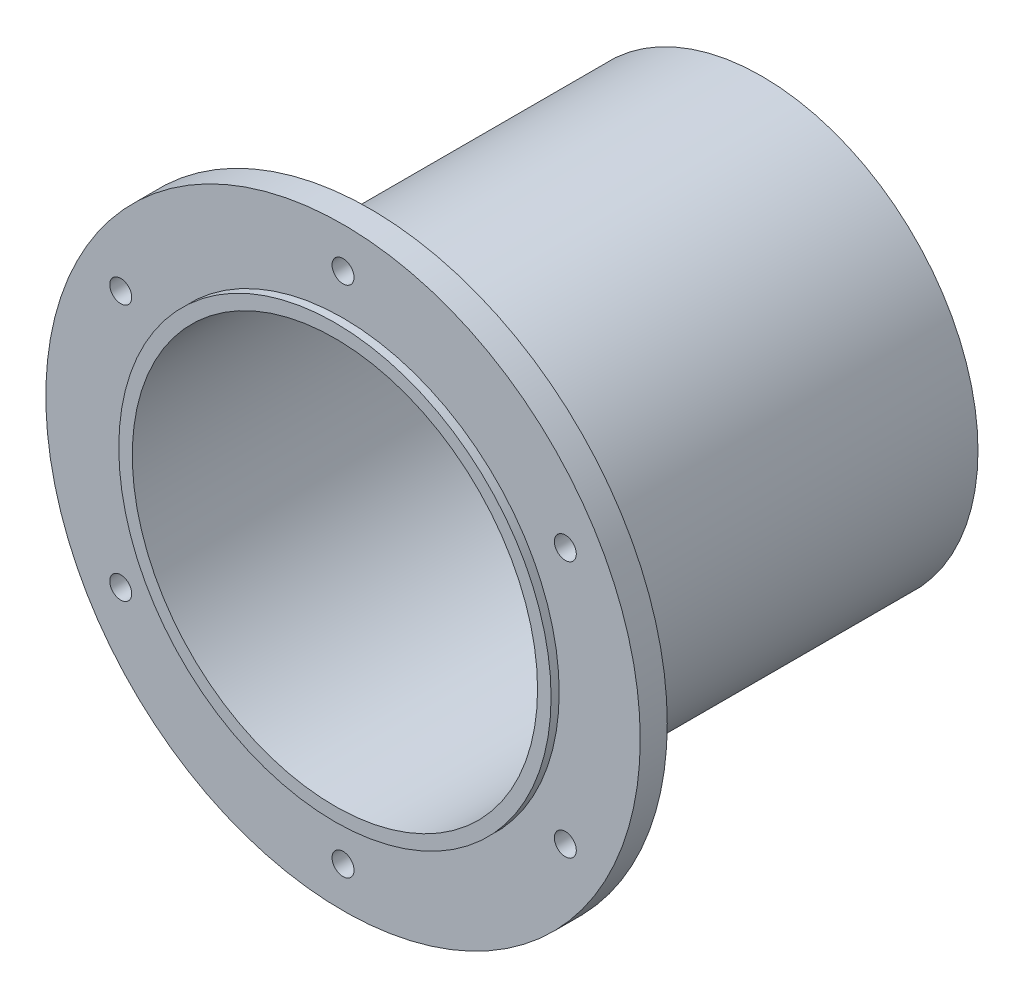
from build123d import *

# Parameters (mm, degrees)
SKETCH1_R           = 69.85
SKETCH1_R_2         = 50.8
SKETCH1_R_3         = 2.57937
EXTRUDE1_DEPTH      = 6.35
SKETCH2_R           = 50.8
SKETCH2_R_2         = 47.625
EXTRUDE2_DEPTH      = 8.255
EXTRUDE2_DEPTH_BACK = 92.075


with BuildPart() as part:
    # Sketch1 → Extrude1 (new body)
    with BuildSketch(Plane.XY):
        Circle(SKETCH1_R)
        Circle(SKETCH1_R_2, mode=Mode.SUBTRACT)
        with Locations((0, 60.325)):
            Circle(SKETCH1_R_3, mode=Mode.SUBTRACT)
        with Locations((-52.242982483, 30.1625)):
            Circle(SKETCH1_R_3, mode=Mode.SUBTRACT)
        with Locations((-52.242982483, -30.1625)):
            Circle(SKETCH1_R_3, mode=Mode.SUBTRACT)
        with Locations((0, -60.325)):
            Circle(SKETCH1_R_3, mode=Mode.SUBTRACT)
        with Locations((52.242982483, -30.1625)):
            Circle(SKETCH1_R_3, mode=Mode.SUBTRACT)
        with Locations((52.242982483, 30.1625)):
            Circle(SKETCH1_R_3, mode=Mode.SUBTRACT)
    extrude(amount=EXTRUDE1_DEPTH)


with BuildPart() as body_2:
    # Sketch2 → Extrude2 (new body, two sides)
    with BuildSketch(Plane.XY) as extrude2_sk:
        Circle(SKETCH2_R)
        Circle(SKETCH2_R_2, mode=Mode.SUBTRACT)
    extrude(amount=EXTRUDE2_DEPTH)
    extrude(extrude2_sk.sketch, amount=-EXTRUDE2_DEPTH_BACK)


solid = Compound([part.part, body_2.part])
